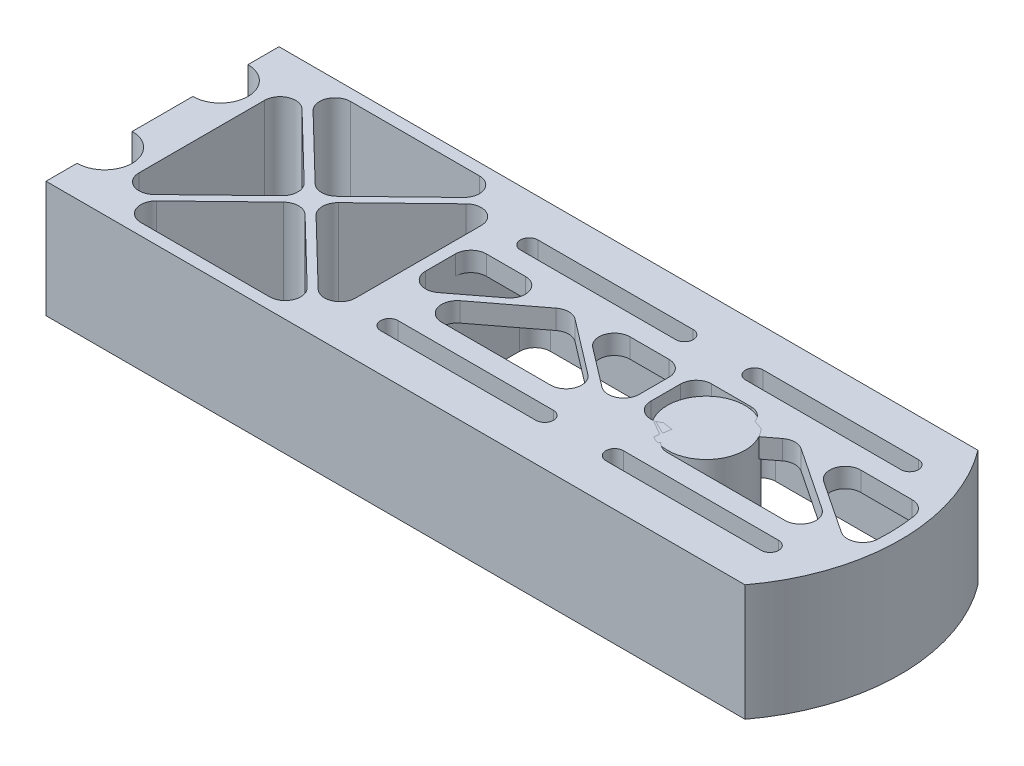
from build123d import *

# Parameters (mm, degrees)
EXTRUDE_1_DEPTH      = 30
CUT_EXTRUDE_1_DEPTH  = 31
TEMP_R               = 10
EXTRUDE_2_DEPTH      = 30
EXTRUDE_3_DEPTH      = 5
EXTRUDE_4_DEPTH      = 30
SKETCH_6_W           = 3
SKETCH_6_H           = 54
EXTRUDE_5_DEPTH      = 30
EXTRUDE_6_DEPTH      = 30
SKETCH_9_W           = 3
SKETCH_9_H           = 54
EXTRUDE_8_DEPTH      = 25
EXTRUDE_8_DEPTH_BACK = 5
EXTRUDE_7_DEPTH      = 5
FILLET_1_R           = 4
FILLET_2_R           = 4
FILLET_3_R           = 4
EXTRUDE_9_DEPTH      = 5


with BuildPart() as part:
    # Эскиз1 → Бобышка-Вытянуть1 (new body)
    with BuildSketch(Plane(origin=(0, 0, 0), x_dir=(1, 0, 0), z_dir=(0, 1, 0))):
        with BuildLine():
            Line((0, 60), (180, 60))
            ThreePointArc((180, 60), (190, 30), (180, 0))
            Line((180, 0), (0, 0))
            Line((0, 0), (0, 8))
            ThreePointArc((0, 8), (7.1, 15.1), (0, 22.2))
            Line((0, 22.2), (0, 37.8))
            ThreePointArc((0, 37.8), (7.1, 44.9), (0, 52))
            Line((0, 52), (0, 60))
        make_face()
    extrude(amount=EXTRUDE_1_DEPTH)

    # Эскиз2 → Вырез-Вытянуть1 (cut, through all)
    with BuildSketch(Plane(origin=(0, 30, 0), x_dir=(1, 0, 0), z_dir=(0, 1, 0))):
        with BuildLine():
            Line((3, 3), (178.470768123, 3))
            ThreePointArc((178.470768123, 3), (187, 30), (178.470768123, 57))
            Line((178.470768123, 57), (3, 57))
            Line((3, 57), (3, 54.544169223))
            ThreePointArc((3, 54.544169223), (10.1, 44.9), (3, 35.255830777))
            Line((3, 35.255830777), (3, 24.744169223))
            ThreePointArc((3, 24.744169223), (10.1, 15.1), (3, 5.455830777))
            Line((3, 5.455830777), (3, 3))
        make_face()
    extrude(amount=-CUT_EXTRUDE_1_DEPTH, mode=Mode.SUBTRACT)

    # Эскиз3 → Бобышка-Вытянуть3 (add)
    with BuildSketch(Plane(origin=(0, 30, 0), x_dir=(1, 0, 0), z_dir=(0, 1, 0))):
        with BuildLine():
            Line((178.470768123, 57), (68.916586692, 57))
            Line((68.916586692, 57), (68.916586692, 40.5))
            Line((68.916586692, 40.5), (185.812116301, 40.5))
            ThreePointArc((185.812116301, 40.5), (182.941397878, 49.105924428), (178.470768123, 57))
        make_face()
        with BuildLine():
            Line((116.416586692, 43.5), (76.416586692, 43.5))
            ThreePointArc((76.416586692, 43.5), (71.916586692, 48), (76.416586692, 52.5))
            Line((76.416586692, 52.5), (116.416586692, 52.5))
            ThreePointArc((116.416586692, 52.5), (120.916586692, 48), (116.416586692, 43.5))
        make_face(mode=Mode.SUBTRACT)
        with BuildLine():
            ThreePointArc((174.416586692, 52.5), (178.916586692, 48), (174.416586692, 43.5))
            Line((174.416586692, 43.5), (134.416586692, 43.5))
            ThreePointArc((134.416586692, 43.5), (129.916586692, 48), (134.416586692, 52.5))
            Line((134.416586692, 52.5), (174.416586692, 52.5))
        make_face(mode=Mode.SUBTRACT)
        with BuildLine():
            ThreePointArc((178.470768123, 3), (182.941397878, 10.894075572), (185.812116301, 19.5))
            Line((185.812116301, 19.5), (68.916586692, 19.5))
            Line((68.916586692, 19.5), (68.916586692, 3))
            Line((68.916586692, 3), (178.470768123, 3))
        make_face()
        with BuildLine():
            ThreePointArc((76.416586692, 7.5), (71.916586692, 12), (76.416586692, 16.5))
            Line((76.416586692, 16.5), (116.416586692, 16.5))
            ThreePointArc((116.416586692, 16.5), (120.916586692, 12), (116.416586692, 7.5))
            Line((116.416586692, 7.5), (76.416586692, 7.5))
        make_face(mode=Mode.SUBTRACT)
        with BuildLine():
            Line((134.416586692, 16.5), (174.416586692, 16.5))
            ThreePointArc((174.416586692, 16.5), (178.916586692, 12), (174.416586692, 7.5))
            Line((174.416586692, 7.5), (134.416586692, 7.5))
            ThreePointArc((134.416586692, 7.5), (129.916586692, 12), (134.416586692, 16.5))
        make_face(mode=Mode.SUBTRACT)
    extrude(amount=-EXTRUDE_3_DEPTH)

    # Эскиз4 → Бобышка-Вытянуть4 (add, through all)
    with BuildSketch(Plane(origin=(0, 30, 0), x_dir=(1, 0, 0), z_dir=(0, 1, 0))):
        with BuildLine():
            Line((10.1, 57), (3, 57))
            Line((3, 57), (3, 54.544169223))
            ThreePointArc((3, 54.544169223), (8.133572401, 50.887904475), (10.1, 44.9))
            Line((10.1, 44.9), (10.1, 57))
        make_face()
        with BuildLine():
            Line((10.1, 15.100000017), (10.1, 44.9))
            ThreePointArc((10.1, 44.9), (8.133572401, 38.912095525), (3, 35.255830777))
            Line((3, 35.255830777), (3, 24.744169223))
            ThreePointArc((3, 24.744169223), (8.133572396, 21.087904482), (10.1, 15.100000017))
        make_face()
        with BuildLine():
            Line((10.1, 3), (10.1, 15.100000017))
            ThreePointArc((10.1, 15.100000017), (8.133572406, 9.112095532), (3, 5.455830777))
            Line((3, 5.455830777), (3, 3))
            Line((3, 3), (10.1, 3))
        make_face()
    extrude(amount=-EXTRUDE_4_DEPTH)

    # Эскиз6 → Бобышка-Вытянуть5 (add, through all)
    with BuildSketch(Plane(origin=(0, 30, 0), x_dir=(1, 0, 0), z_dir=(0, 1, 0))):
        with Locations((67.416586692, 30)):
            Rectangle(SKETCH_6_W, SKETCH_6_H)
    extrude(amount=-EXTRUDE_5_DEPTH)

    # Эскиз7 → Бобышка-Вытянуть6 (add, through all)
    with BuildSketch(Plane(origin=(0, 30, 0), x_dir=(1, 0, 0), z_dir=(0, 1, 0))):
        Polygon((10.1, 55.608609353), (36.57009563, 30), (10.1, 4.391390647), (10.1, 3), (11.538197716, 3), (38.008293346, 28.608609353), (64.478388976, 3), (65.916586692, 3), (65.916586692, 4.391390647), (39.446491062, 30), (65.916586692, 55.608609353), (65.916586692, 57), (64.478388976, 57), (38.008293346, 31.391390647), (11.538197716, 57), (10.1, 57), align=None)
    extrude(amount=-EXTRUDE_6_DEPTH)

    # Эскиз9 → Бобышка-Вытянуть8 (add, two sides)
    with BuildSketch(Plane.XZ.offset(-25)) as extrude_8_sk:
        with Locations((125.416586692, -30)):
            Rectangle(SKETCH_9_W, SKETCH_9_H)
    extrude(amount=EXTRUDE_8_DEPTH)
    extrude(extrude_8_sk.sketch, amount=-EXTRUDE_8_DEPTH_BACK)

    # Эскиз8 → Бобышка-Вытянуть7 (add)
    with BuildSketch(Plane(origin=(0, 30, 0), x_dir=(1, 0, 0), z_dir=(0, 1, 0))):
        Polygon((70.564267671, 19.5), (96.416586692, 39.241770889), (122.268905713, 19.5), (123.916586692, 19.5), (123.916586692, 20.758229111), (98.064267671, 40.5), (94.768905713, 40.5), (68.916586692, 20.758229111), (68.916586692, 19.5), align=None)
        with BuildLine():
            Line((128.569887735, 19.5), (154.477979009, 39.178204914))
            Line((154.477979009, 39.178204914), (184.008770478, 19.5))
            Line((184.008770478, 19.5), (185.812116301, 19.5))
            ThreePointArc((185.812116301, 19.5), (185.929117822, 20.024222532), (186.040120933, 20.549747915))
            Line((186.040120933, 20.549747915), (156.101072293, 40.5))
            Line((156.101072293, 40.5), (152.911636662, 40.5))
            Line((152.911636662, 40.5), (126.916586692, 20.755746568))
            Line((126.916586692, 20.755746568), (126.916586692, 19.5))
            Line((126.916586692, 19.5), (128.569887735, 19.5))
        make_face()
    extrude(amount=-EXTRUDE_7_DEPTH)

    # Скругление1
    fillet_1_edges = [part.edges().sort_by_distance(p)[0] for p in [
        (10.1, 15, -4.391390647),
        (36.57009563, 15, -30),
        (10.1, 15, -55.608609353),
        (11.538197716, 15, -57),
        (38.008293346, 15, -31.391390647),
        (64.478388976, 15, -57),
        (65.916586692, 15, -55.608609353),
        (39.446491062, 15, -30),
        (65.916586692, 15, -4.391390647),
        (64.478388976, 15, -3),
        (38.008293346, 15, -28.608609353),
        (11.538197716, 15, -3),
    ]]
    fillet(fillet_1_edges, radius=FILLET_1_R)

    # Скругление2
    fillet_2_edges = [part.edges().sort_by_distance(p)[0] for p in [
        (68.916586692, 12.5, -57),
        (68.916586692, 12.5, -3),
        (123.916586692, 12.5, -57),
        (126.916586692, 12.5, -3),
        (123.916586692, 12.5, -3),
        (126.916586692, 12.5, -57),
        (178.470768123, 12.5, -57),
        (178.470768123, 12.5, -3),
    ]]
    fillet(fillet_2_edges, radius=FILLET_2_R)

    # Скругление3
    fillet_3_edges = [part.edges().sort_by_distance(p)[0] for p in [
        (123.916586692, 27.5, -40.5),
        (126.916586692, 27.5, -40.5),
        (70.564267671, 27.5, -19.5),
        (68.916586692, 27.5, -20.758229111),
        (94.768905713, 27.5, -40.5),
        (98.064267671, 27.5, -40.5),
        (123.916586692, 27.5, -20.758229111),
        (122.268905713, 27.5, -19.5),
        (96.416586692, 27.5, -39.241770889),
        (128.569887735, 27.5, -19.5),
        (126.916586692, 27.5, -20.755746568),
        (152.911636662, 27.5, -40.5),
        (156.101072293, 27.5, -40.5),
        (186.040120933, 27.5, -20.549747915),
        (184.008770478, 27.5, -19.5),
        (154.477979009, 27.5, -39.178204914),
        (68.916586692, 27.5, -40.5),
        (185.812116301, 27.5, -40.5),
    ]]
    fillet(fillet_3_edges, radius=FILLET_3_R)

    # Эскиз10 → Бобышка-Вытянуть9 (add)
    with BuildSketch(Plane(origin=(0, 30, 0), x_dir=(1, 0, 0), z_dir=(0, 1, 0))):
        with BuildLine():
            Line((76.416586692, 52.5), (116.416586692, 52.5))
            ThreePointArc((116.416586692, 52.5), (120.916586692, 48), (116.416586692, 43.5))
            Line((116.416586692, 43.5), (76.416586692, 43.5))
            ThreePointArc((76.416586692, 43.5), (71.916586692, 48), (76.416586692, 52.5))
        make_face()
        with BuildLine():
            Line((116.416586692, 50.25), (76.416586692, 50.25))
            ThreePointArc((76.416586692, 50.25), (74.166586692, 48), (76.416586692, 45.75))
            Line((76.416586692, 45.75), (116.416586692, 45.75))
            ThreePointArc((116.416586692, 45.75), (118.666586692, 48), (116.416586692, 50.25))
        make_face(mode=Mode.SUBTRACT)
        with BuildLine():
            Line((174.416586692, 52.5), (134.416586692, 52.5))
            ThreePointArc((134.416586692, 52.5), (129.916586692, 48), (134.416586692, 43.5))
            Line((134.416586692, 43.5), (174.416586692, 43.5))
            ThreePointArc((174.416586692, 43.5), (178.916586692, 48), (174.416586692, 52.5))
        make_face()
        with BuildLine():
            Line((174.416586692, 45.75), (134.416586692, 45.75))
            ThreePointArc((134.416586692, 45.75), (132.166586692, 48), (134.416586692, 50.25))
            Line((134.416586692, 50.25), (174.416586692, 50.25))
            ThreePointArc((174.416586692, 50.25), (176.666586692, 48), (174.416586692, 45.75))
        make_face(mode=Mode.SUBTRACT)
        with BuildLine():
            Line((76.416586692, 16.5), (116.416586692, 16.5))
            ThreePointArc((116.416586692, 16.5), (120.916586692, 12), (116.416586692, 7.5))
            Line((116.416586692, 7.5), (76.416586692, 7.5))
            ThreePointArc((76.416586692, 7.5), (71.916586692, 12), (76.416586692, 16.5))
        make_face()
        with BuildLine():
            Line((76.416586692, 9.75), (116.416586692, 9.75))
            ThreePointArc((116.416586692, 9.75), (118.666586692, 12), (116.416586692, 14.25))
            Line((116.416586692, 14.25), (76.416586692, 14.25))
            ThreePointArc((76.416586692, 14.25), (74.166586692, 12), (76.416586692, 9.75))
        make_face(mode=Mode.SUBTRACT)
        with BuildLine():
            Line((174.416586692, 16.5), (134.416586692, 16.5))
            ThreePointArc((134.416586692, 16.5), (129.916586692, 12), (134.416586692, 7.5))
            Line((134.416586692, 7.5), (174.416586692, 7.5))
            ThreePointArc((174.416586692, 7.5), (178.916586692, 12), (174.416586692, 16.5))
        make_face()
        with BuildLine():
            Line((174.416586692, 14.25), (134.416586692, 14.25))
            ThreePointArc((134.416586692, 14.25), (132.166586692, 12), (134.416586692, 9.75))
            Line((134.416586692, 9.75), (174.416586692, 9.75))
            ThreePointArc((174.416586692, 9.75), (176.666586692, 12), (174.416586692, 14.25))
        make_face(mode=Mode.SUBTRACT)
    extrude(amount=-EXTRUDE_9_DEPTH)


with BuildPart() as body_2:
    # Temp → Бобышка-Вытянуть2 (new body)
    with BuildSketch(Plane(origin=(0, 30, 0), x_dir=(1, 0, 0), z_dir=(0, 1, 0))):
        with Locations((140, 30)):
            Circle(TEMP_R)
    extrude(amount=-EXTRUDE_2_DEPTH)


solid = Compound([part.part, body_2.part])
